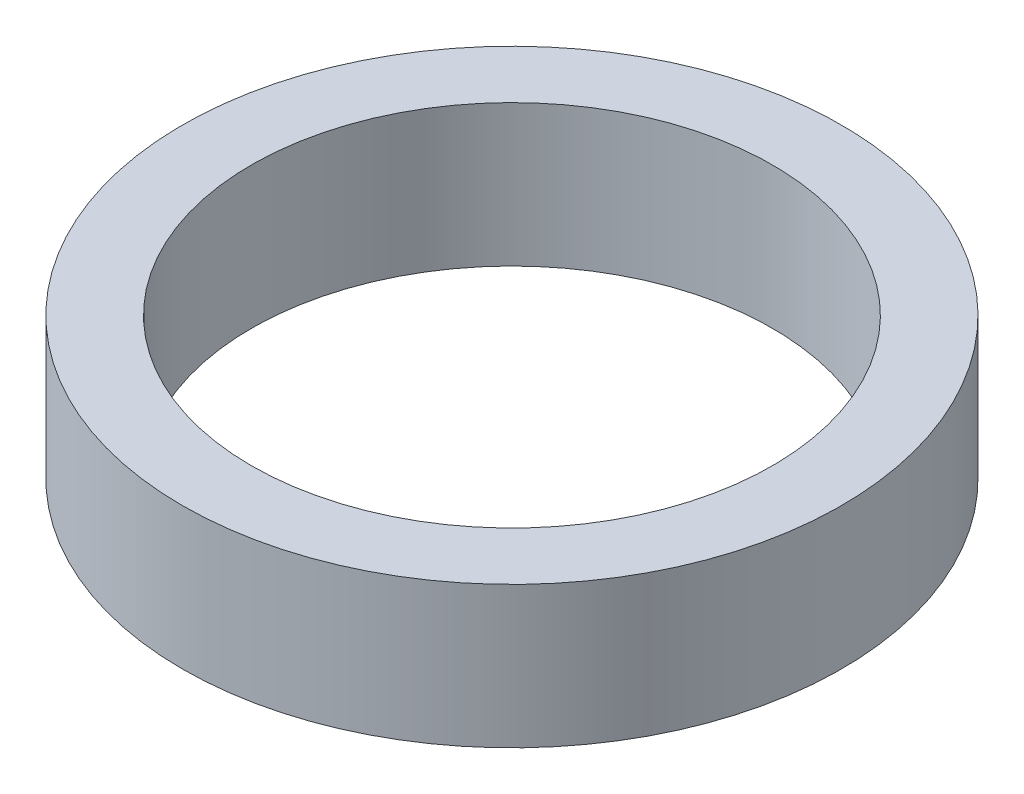
from build123d import *

# Parameters (mm, degrees)
SKETCH1_W = 7.166716326
SKETCH1_H = 14.696640474


with BuildPart() as part:
    # Sketch1 → Revolve1 (revolve)
    with BuildSketch(Plane.XY):
        with Locations((-30.634599911, 0)):
            Rectangle(SKETCH1_W, SKETCH1_H)
    revolve(axis=Axis((0, 21.406491511, 0), (0, -1, 0)))


solid = part.part
